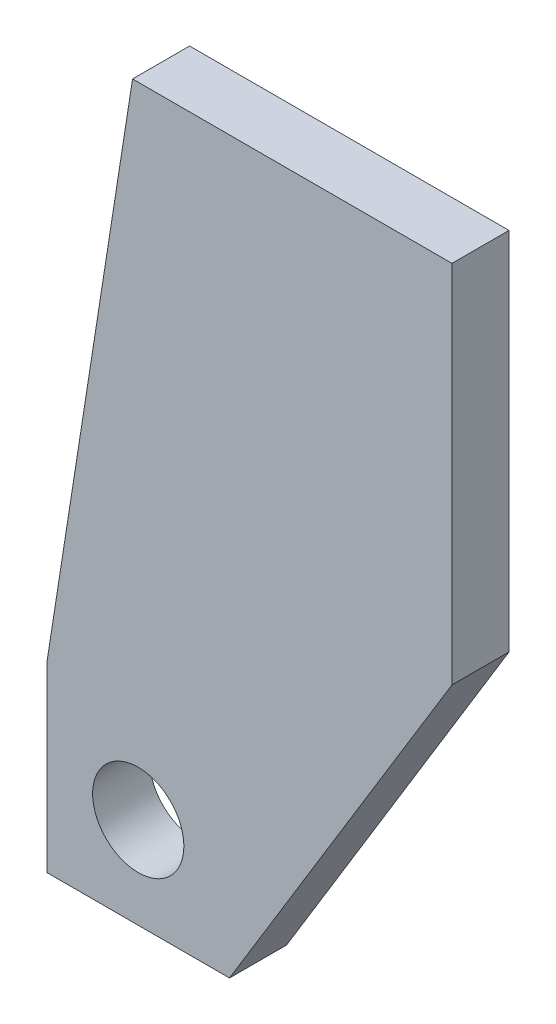
from build123d import *

# Parameters (mm, degrees)
EXTRUDE_START   = 20
SKETCH_1_R      = 4
EXTRUDE_1_DEPTH = 5


with BuildPart() as part:
    # ｽｹｯﾁ1 → ﾎﾞｽ - 押し出し1 (new body)
    with BuildSketch(Plane.XY.offset(EXTRUDE_START)):
        Polygon((0, 22), (16, 22), (35.5, 54), (35.5, 86), (7.5, 86), (0, 38), align=None)
        with Locations((8, 30)):
            Circle(SKETCH_1_R, mode=Mode.SUBTRACT)
    extrude(amount=EXTRUDE_1_DEPTH)


solid = part.part
